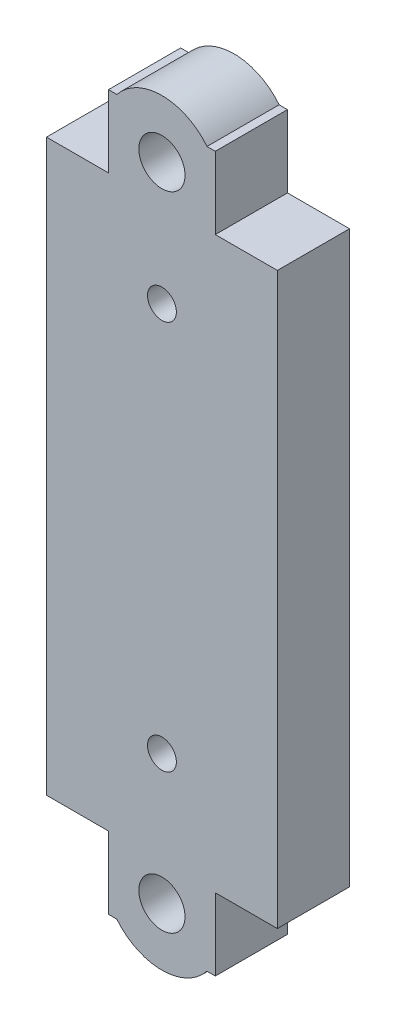
from build123d import *

# Parameters (mm, degrees)
ESQUISSE1_W         = 22
ESQUISSE1_H         = 55.5
ESQUISSE1_R         = 1
ESQUISSE1_W_2       = 5
ESQUISSE1_H_2       = 5
BOSS_EXTRU_1_DEPTH  = 5
SKETCH1_W           = 22
SKETCH1_H           = 55.5
SKETCH1_W_2         = 16
SKETCH1_H_2         = 49.5
CUT_EXTRUDE1_DEPTH  = 10
SKETCH2_W           = 1
SKETCH2_H           = 5
BOSS_EXTRUDE1_DEPTH = 5
SKETCH3_R           = 1.6
CUT_EXTRUDE2_DEPTH  = 10
SKETCH4_R           = 4
SKETCH4_R_2         = 1.6
BOSS_EXTRUDE2_DEPTH = 5
SKETCH5_W           = 0.3
SKETCH5_H           = 5
CUT_EXTRUDE3_DEPTH  = 10


with BuildPart() as part:
    # Esquisse1 → Boss.-Extru.1 (new body)
    with BuildSketch(Plane.XY):
        with Locations((-6.988022113, -13.090909091)):
            Rectangle(ESQUISSE1_W, ESQUISSE1_H)
        with Locations((-6.988022113, 0.659090909)):
            Circle(ESQUISSE1_R, mode=Mode.SUBTRACT)
        with Locations((-6.988022113, -26.340909091)):
            Circle(ESQUISSE1_R, mode=Mode.SUBTRACT)
        with Locations((-12.488022113, -35.340909091)):
            Rectangle(ESQUISSE1_W_2, ESQUISSE1_H_2, mode=Mode.SUBTRACT)
        with Locations((-1.488022113, 9.159090909)):
            Rectangle(ESQUISSE1_W_2, ESQUISSE1_H_2, mode=Mode.SUBTRACT)
        with Locations((-1.488022113, -35.340909091)):
            Rectangle(ESQUISSE1_W_2, ESQUISSE1_H_2, mode=Mode.SUBTRACT)
        with Locations((-12.488022113, 9.159090909)):
            Rectangle(ESQUISSE1_W_2, ESQUISSE1_H_2, mode=Mode.SUBTRACT)
    extrude(amount=BOSS_EXTRU_1_DEPTH)

    # Sketch1 → Cut-Extrude1 (cut)
    with BuildSketch(Plane.XY.offset(5)):
        with Locations((-6.988022113, -13.090909091)):
            Rectangle(SKETCH1_W, SKETCH1_H)
        with Locations((-6.988022113, -13.090909091)):
            Rectangle(SKETCH1_W_2, SKETCH1_H_2, mode=Mode.SUBTRACT)
    extrude(amount=-CUT_EXTRUDE1_DEPTH, mode=Mode.SUBTRACT)

    # Sketch2 → Boss-Extrude1 (add)
    with BuildSketch(Plane.XY.offset(5)):
        with Locations((-3.488022113, -35.340909091)):
            Rectangle(SKETCH2_W, SKETCH2_H)
        with Locations((-10.488022113, -35.340909091)):
            Rectangle(SKETCH2_W, SKETCH2_H)
        with Locations((-3.488022113, 9.159090909)):
            Rectangle(SKETCH2_W, SKETCH2_H)
        with Locations((-10.488022113, 9.159090909)):
            Rectangle(SKETCH2_W, SKETCH2_H)
    extrude(amount=-BOSS_EXTRUDE1_DEPTH)

    # Sketch3 → Cut-Extrude2 (cut)
    with BuildSketch(Plane.XY.offset(5)):
        with Locations((-6.988022113, -35.340909091)):
            Circle(SKETCH3_R)
        with Locations((-6.988022113, 9.159090909)):
            Circle(SKETCH3_R)
    extrude(amount=-CUT_EXTRUDE2_DEPTH, mode=Mode.SUBTRACT)

    # Sketch4 → Boss-Extrude2 (add)
    with BuildSketch(Plane.XY.offset(5)):
        with Locations((-6.988022113, -35.340909091)):
            Circle(SKETCH4_R)
        with Locations((-6.988022113, -35.340909091)):
            Circle(SKETCH4_R_2, mode=Mode.SUBTRACT)
        with Locations((-6.988022113, 9.159090909)):
            Circle(SKETCH4_R)
        with Locations((-6.988022113, 9.159090909)):
            Circle(SKETCH4_R_2, mode=Mode.SUBTRACT)
    extrude(amount=-BOSS_EXTRUDE2_DEPTH)

    # Sketch5 → Cut-Extrude3 (cut)
    with BuildSketch(Plane.XY.offset(5)):
        with Locations((-3.138022113, -35.340909091)):
            Rectangle(SKETCH5_W, SKETCH5_H)
        with Locations((-10.838022113, -35.340909091)):
            Rectangle(SKETCH5_W, SKETCH5_H)
        with Locations((-3.138022113, 9.159090909)):
            Rectangle(SKETCH5_W, SKETCH5_H)
        with Locations((-10.838022113, 9.159090909)):
            Rectangle(SKETCH5_W, SKETCH5_H)
    extrude(amount=-CUT_EXTRUDE3_DEPTH, mode=Mode.SUBTRACT)


solid = part.part
